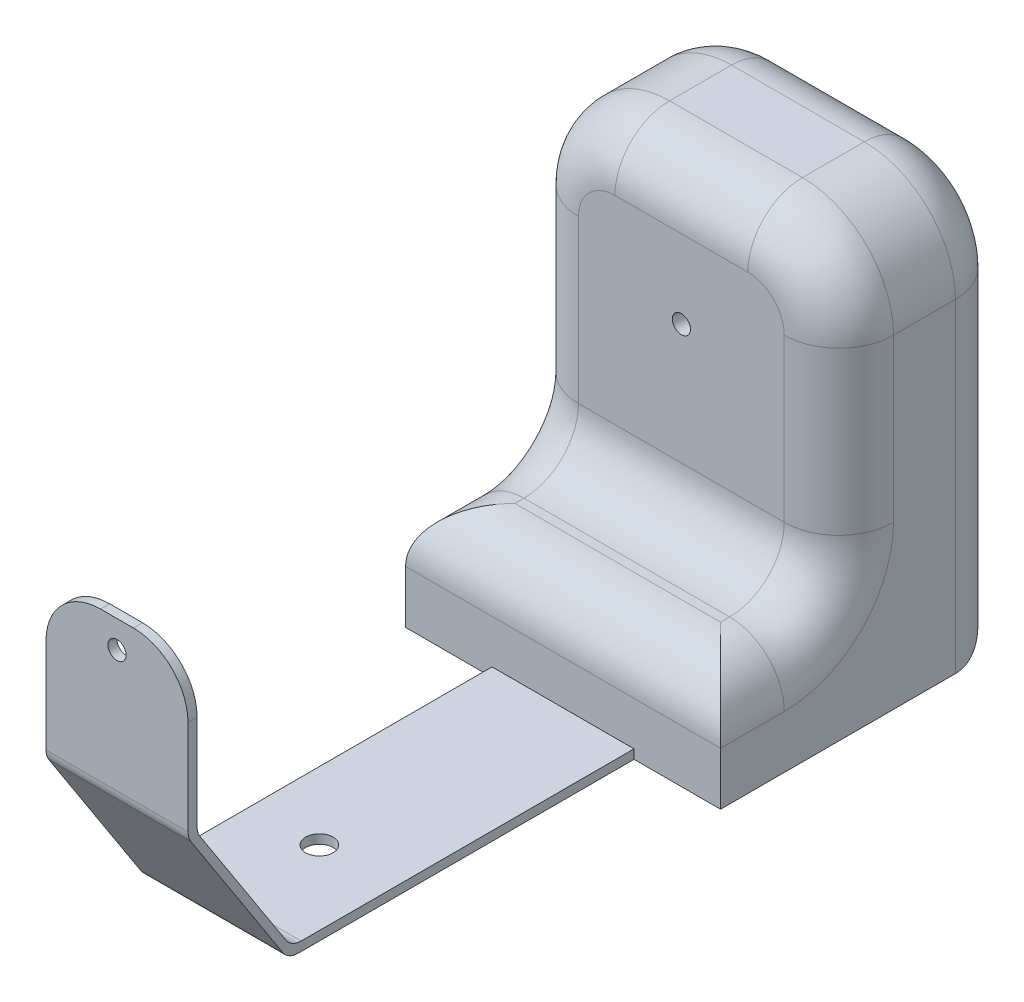
from build123d import *

# Parameters (mm, degrees)
EXTRUDE1_DEPTH = 78
FILLET1_R      = 20
FILLET2_R      = 10
SKETCH3_R      = 7.5
EXTRUDE3_DEPTH = 6
FILLET3_R      = 30
SKETCH4_W      = 276.639181173
SKETCH4_H      = 310.570393871
EXTRUDE4_DEPTH = 79
SKETCH5_W      = 173
SKETCH5_H      = 59
EXTRUDE5_DEPTH = 65
EXTRUDE6_DEPTH = 94
SKETCH2_R      = 5
EXTRUDE2_DEPTH = 405
FILLET4_R      = 30
FILLET5_R      = 30


with BuildPart() as part:
    # Sketch1 → Extrude1 (new body)
    with BuildSketch(Plane(origin=(0, 0, 0), x_dir=(0, 0, -1), z_dir=(1, 0, 0))):
        Polygon((-38.878108718, 93.787762145), (-38.878108718, 8.787762145), (16.121891282, -76.212237855), (361.121891282, -76.212237855), (361.121891282, 123.787762145), (356.121891282, 123.787762145), (356.121891282, -71.212237855), (17.886597165, -71.212237855), (-33.878108718, 8.787762145), (-33.878108718, 93.787762145), align=None)
    extrude(amount=EXTRUDE1_DEPTH)

    # Fillet1
    fillet1_edges = [part.edges().sort_by_distance(p)[0] for p in [
        (39, -71.212237855, -356.121891282),
        (39, -76.212237855, -361.121891282),
    ]]
    fillet(fillet1_edges, radius=FILLET1_R)

    # Fillet2
    fillet2_edges = [part.edges().sort_by_distance(p)[0] for p in [
        (39, 8.787762145, 33.878108718),
        (39, -71.212237855, -17.886597165),
        (39, -76.212237855, -16.121891282),
        (39, 8.787762145, 38.878108718),
    ]]
    fillet(fillet2_edges, radius=FILLET2_R)

    # Sketch3 → Extrude3 (cut, through all)
    with BuildSketch(Plane(origin=(0, -71.212237855, 0), x_dir=(1, 0, 0), z_dir=(0, 1, 0))):
        with Locations((37.276272586, 74.00186583)):
            Circle(SKETCH3_R)
    extrude(amount=-EXTRUDE3_DEPTH, mode=Mode.SUBTRACT)

    # Fillet3
    fillet3_edges = [part.edges().sort_by_distance(p)[0] for p in [
        (0, 93.787762145, 36.378108718),
        (78, 93.787762145, 36.378108718),
    ]]
    fillet(fillet3_edges, radius=FILLET3_R)

    # Sketch4 → Extrude4 (cut, through all)
    with BuildSketch(Plane(origin=(78, 0, 0), x_dir=(0, 0, -1), z_dir=(1, 0, 0))):
        with Locations((344.441481869, 21.193022351)):
            Rectangle(SKETCH4_W, SKETCH4_H)
    extrude(amount=-EXTRUDE4_DEPTH, mode=Mode.SUBTRACT)

    # Sketch5 → Extrude5 (add)
    with BuildSketch(Plane(origin=(0, 0, -206.121891282), x_dir=(-1, 0, 0), z_dir=(0, 0, -1))):
        with Locations((-39, -46.712237855)):
            Rectangle(SKETCH5_W, SKETCH5_H)
    extrude(amount=EXTRUDE5_DEPTH)

    # Sketch6 → Extrude6 (add)
    with BuildSketch(Plane(origin=(0, 0, -271.121891282), x_dir=(-1, 0, 0), z_dir=(0, 0, -1))):
        with BuildLine():
            Line((-125.5, -76.212237855), (47.5, -76.212237855))
            Line((47.5, -76.212237855), (47.5, 101.787762145))
            ThreePointArc((47.5, 101.787762145), (32.855339059, 137.143101205), (-2.5, 151.787762145))
            Line((-2.5, 151.787762145), (-75.5, 151.787762145))
            ThreePointArc((-75.5, 151.787762145), (-110.855339059, 137.143101205), (-125.5, 101.787762145))
            Line((-125.5, 101.787762145), (-125.5, -76.212237855))
        make_face()
    extrude(amount=EXTRUDE6_DEPTH)

    # Sketch2 → Extrude2 (cut, through all)
    with BuildSketch(Plane.XY.offset(38.878108718)):
        with Locations((39, 78.787762145)):
            Circle(SKETCH2_R)
    extrude(amount=-EXTRUDE2_DEPTH, mode=Mode.SUBTRACT)

    # Fillet4
    fillet4_edges = [part.edges().sort_by_distance(p)[0] for p in [
        (125.5, -17.212237855, -238.621891282),
        (39, -17.212237855, -206.121891282),
        (-47.5, -17.212237855, -238.621891282),
        (39, -17.212237855, -271.121891282),
        (125.5, 42.287762145, -271.121891282),
        (-47.5, 42.287762145, -271.121891282),
        (-32.855339059, 137.143101205, -271.121891282),
        (39, 151.787762145, -271.121891282),
        (110.855339059, 137.143101205, -271.121891282),
    ]]
    fillet(fillet4_edges, radius=FILLET4_R)

    # Fillet5
    fillet5_edges = [part.edges().sort_by_distance(p)[0] for p in [
        (125.5, 12.787762145, -365.121891282),
        (39, -76.212237855, -365.121891282),
        (-47.5, 12.787762145, -365.121891282),
        (-32.855339059, 137.143101205, -365.121891282),
        (39, 151.787762145, -365.121891282),
        (110.855339059, 137.143101205, -365.121891282),
    ]]
    fillet(fillet5_edges, radius=FILLET5_R)


solid = part.part
